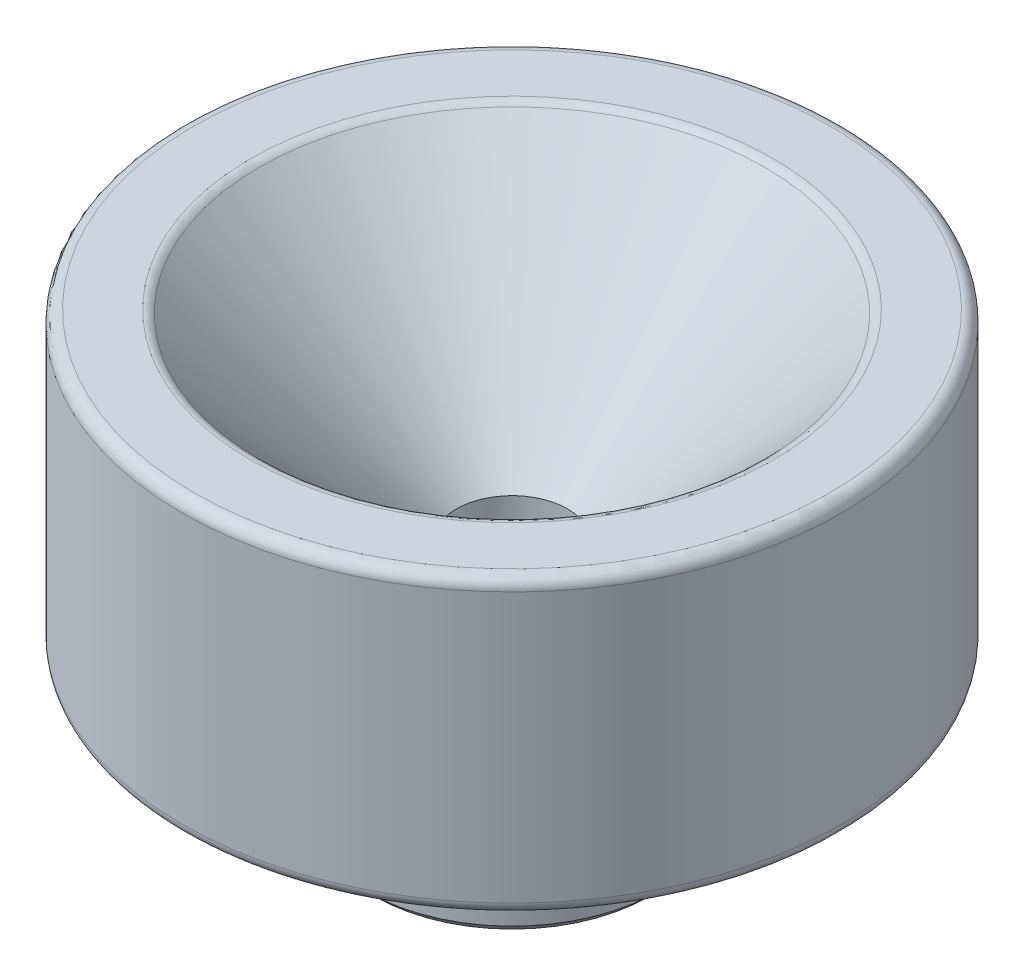
from build123d import *

# Parameters (mm, degrees)
SKETCH2_R     = 0.762
CHAMFER1_SIZE = 0.381
FILLET1_R     = 0.508
CHAMFER2_SIZE = 0.381


with BuildPart() as part:
    # Sketch1 → Revolve1 (revolve)
    with BuildSketch(Plane.XY, mode=Mode.PRIVATE) as revolve1_sk:
        Polygon((2.413, -6.35), (6.35, -6.35), (6.35, 0), (14.2875, 0), (14.2875, 12.7), (11.1125, 12.7), (2.413, 4.0005), align=None)
    revolve(revolve1_sk.sketch.rotate(Axis((0, 0, 0), (0, 1, 0)), 90), axis=Axis((0, 0, 0), (0, 1, 0)))  # turned: the seam where the file's is

    # Sketch2 → Cut-Revolve1 (revolve, cut)
    with BuildSketch(Plane.XY, mode=Mode.PRIVATE) as cut_revolve1_sk:
        with Locations((6.858, -0.508)):
            Circle(SKETCH2_R)
    revolve(cut_revolve1_sk.sketch.rotate(Axis((0, 0, 0), (0, -1, 0)), 270), axis=Axis((0, 0, 0), (0, -1, 0)), mode=Mode.SUBTRACT)  # turned: the seam where the file's is

    # Chamfer1
    chamfer1_edges = [part.edges().sort_by_distance(p)[0] for p in [
        (0, -6.35, 2.413),
    ]]
    chamfer(chamfer1_edges, length=CHAMFER1_SIZE)

    # Fillet1
    fillet1_edges = [part.edges().sort_by_distance(p)[0] for p in [
        (0, 0, 14.2875),
        (0, 12.7, 14.2875),
        (0, 12.7, 11.1125),
    ]]
    fillet(fillet1_edges, radius=FILLET1_R)

    # Chamfer2
    chamfer2_edges = [part.edges().sort_by_distance(p)[0] for p in [
        (0, -6.35, 6.35),
    ]]
    chamfer(chamfer2_edges, length=CHAMFER2_SIZE)


solid = part.part
